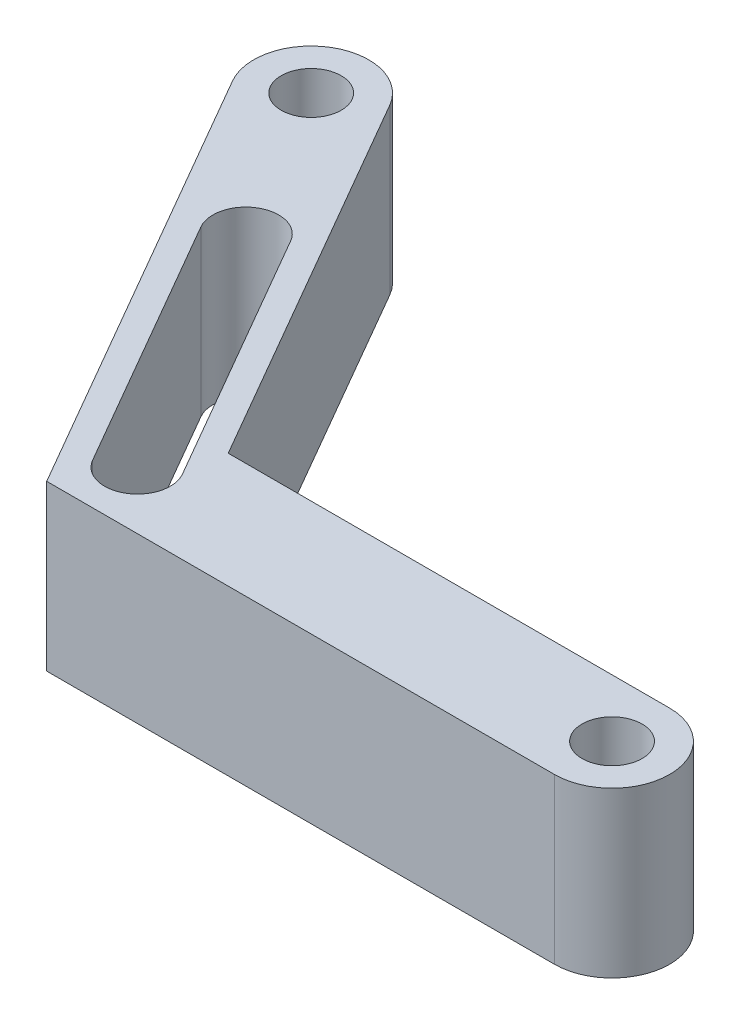
from build123d import *

# Parameters (mm, degrees)
SKIZZE2_R                       = 1.825
AUFSATZ_LINEAR_AUSTRAGEN1_DEPTH = 10
SCHNITT_LINEAR_AUSTRAGEN1_DEPTH = 11


with BuildPart() as part:
    # Skizze2 → Aufsatz-Linear austragen1 (new body)
    with BuildSketch(Plane(origin=(0, 0, 0), x_dir=(1, 0, 0), z_dir=(0, 1, 0))):
        with BuildLine():
            Line((0, 3.5), (-26.846787517, 3.5))
            Line((-26.846787517, 3.5), (-40.270181276, 26.75))
            ThreePointArc((-40.270181276, 26.75), (-45.051270189, 28.031088913), (-46.332359102, 23.25))
            Line((-46.332359102, 23.25), (-30.888239402, -3.5))
            Line((-30.888239402, -3.5), (0, -3.5))
            ThreePointArc((0, -3.5), (3.5, 0), (0, 3.5))
        make_face()
        with Locations((-43.301270189, 25)):
            Circle(SKIZZE2_R, mode=Mode.SUBTRACT)
        Circle(SKIZZE2_R, mode=Mode.SUBTRACT)
    extrude(amount=AUFSATZ_LINEAR_AUSTRAGEN1_DEPTH)

    # Skizze4 → Schnitt-Linear austragen1 (cut, through all)
    with BuildSketch(Plane(origin=(0, 10, 0), x_dir=(1, 0, 0), z_dir=(0, 1, 0))):
        with BuildLine():
            Line((-36.135462652, 16.588457268), (-27.135462652, 1))
            ThreePointArc((-27.135462652, 1), (-27.867513459, -1.732050808), (-30.599564267, -1))
            Line((-30.599564267, -1), (-39.599564267, 14.588457268))
            ThreePointArc((-39.599564267, 14.588457268), (-38.867513459, 17.320508076), (-36.135462652, 16.588457268))
        make_face()
    extrude(amount=-SCHNITT_LINEAR_AUSTRAGEN1_DEPTH, mode=Mode.SUBTRACT)


solid = part.part
